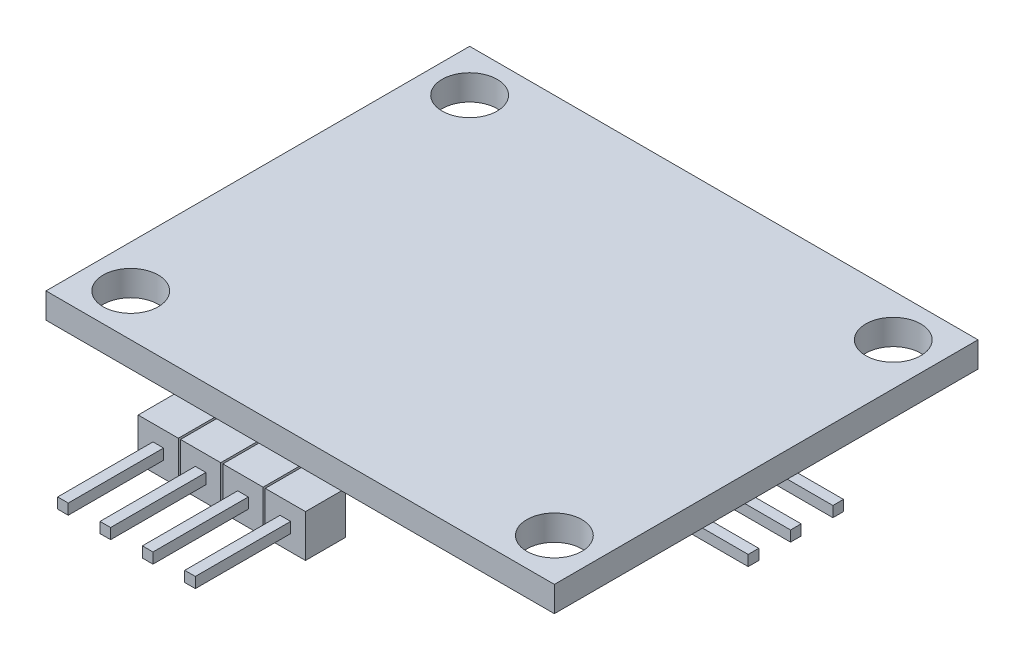
from build123d import *

# Parameters (mm, degrees)
SKETCH1_W           = 30.48
SKETCH1_H           = 25.4
SKETCH1_R           = 1.651
BOSS_EXTRUDE1_DEPTH = 1.524
SKETCH3_W           = 2.413
SKETCH3_H           = 2.413
BOSS_EXTRUDE2_DEPTH = 2.54
SKETCH4_W           = 0.635
SKETCH4_H           = 0.635
BOSS_EXTRUDE3_DEPTH = 5.715
SKETCH5_W           = 0.635
SKETCH5_H           = 0.635
BOSS_EXTRUDE4_DEPTH = 5.715


with BuildPart() as part:
    # Sketch1 → Boss-Extrude1 (new body)
    with BuildSketch(Plane(origin=(0, 0, 0), x_dir=(1, 0, 0), z_dir=(0, 1, 0))):
        with Locations((15.24, 12.7)):
            Rectangle(SKETCH1_W, SKETCH1_H)
        with Locations((2.54, 22.86)):
            Circle(SKETCH1_R, mode=Mode.SUBTRACT)
        with Locations((27.94, 22.86)):
            Circle(SKETCH1_R, mode=Mode.SUBTRACT)
        with Locations((27.94, 2.54)):
            Circle(SKETCH1_R, mode=Mode.SUBTRACT)
        with Locations((2.54, 2.54)):
            Circle(SKETCH1_R, mode=Mode.SUBTRACT)
    extrude(amount=BOSS_EXTRUDE1_DEPTH)

    # Sketch3 → Boss-Extrude2 (add)
    with BuildSketch(Plane(origin=(0, 0, 0), x_dir=(-1, 0, 0), z_dir=(0, -1, 0))):
        with Locations((-25.3365, 10.16)):
            Rectangle(SKETCH3_W, SKETCH3_H)
        with Locations((-25.3365, 12.7)):
            Rectangle(SKETCH3_W, SKETCH3_H)
        with Locations((-25.3365, 15.24)):
            Rectangle(SKETCH3_W, SKETCH3_H)
        with Locations((-16.51, -0.9525)):
            Rectangle(SKETCH3_W, SKETCH3_H)
        with Locations((-13.97, -0.9525)):
            Rectangle(SKETCH3_W, SKETCH3_H)
        with Locations((-11.43, -0.9525)):
            Rectangle(SKETCH3_W, SKETCH3_H)
        with Locations((-8.89, -0.9525)):
            Rectangle(SKETCH3_W, SKETCH3_H)
    extrude(amount=BOSS_EXTRUDE2_DEPTH)

    # Sketch4 → Boss-Extrude3 (add)
    with BuildSketch(Plane.XY.offset(2.159)):
        with Locations((8.89, -1.27)):
            Rectangle(SKETCH4_W, SKETCH4_H)
        with Locations((11.43, -1.27)):
            Rectangle(SKETCH4_W, SKETCH4_H)
        with Locations((13.97, -1.27)):
            Rectangle(SKETCH4_W, SKETCH4_H)
        with Locations((16.51, -1.27)):
            Rectangle(SKETCH4_W, SKETCH4_H)
    extrude(amount=BOSS_EXTRUDE3_DEPTH)

    # Sketch5 → Boss-Extrude4 (add)
    with BuildSketch(Plane(origin=(26.543, 0, 0), x_dir=(0, 0, -1), z_dir=(1, 0, 0))):
        with Locations((10.16, -1.27)):
            Rectangle(SKETCH5_W, SKETCH5_H)
        with Locations((12.7, -1.27)):
            Rectangle(SKETCH5_W, SKETCH5_H)
        with Locations((15.24, -1.27)):
            Rectangle(SKETCH5_W, SKETCH5_H)
    extrude(amount=BOSS_EXTRUDE4_DEPTH)


solid = part.part
